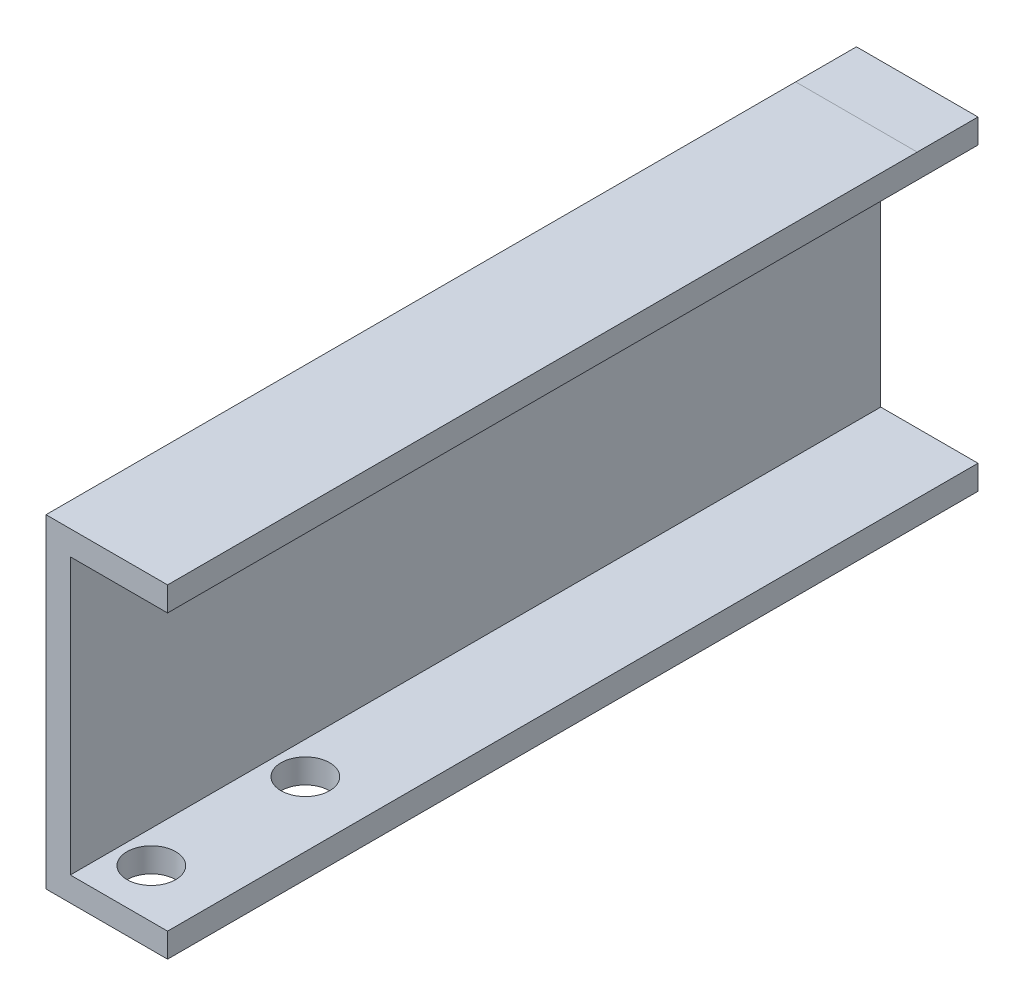
from build123d import *

# Parameters (mm, degrees)
LINEAR_AUSTRAGEN_D_NN1_DEPTH    = 200
SKIZZE2_R                       = 6
SCHNITT_LINEAR_AUSTRAGEN1_DEPTH = 60


with BuildPart() as part:
    # Skizze1 → Linear-Austragen-Dünn1 (new body)
    with BuildSketch(Plane.XY):
        Polygon((30, 40), (0, 40), (0, -40), (30, -40), (30, -34), (6, -34), (6, 34), (30, 34), align=None)
    extrude(amount=-LINEAR_AUSTRAGEN_D_NN1_DEPTH)

    # Skizze2 → Schnitt-Linear austragen1 (cut)
    with BuildSketch(Plane(origin=(0, 0, 0), x_dir=(1, 0, 0), z_dir=(0, 1, 0))):
        with Locations((14, 50)):
            Circle(SKIZZE2_R)
        with Locations((14, 12)):
            Circle(SKIZZE2_R)
    extrude(amount=-SCHNITT_LINEAR_AUSTRAGEN1_DEPTH, mode=Mode.SUBTRACT)


solid = part.part
